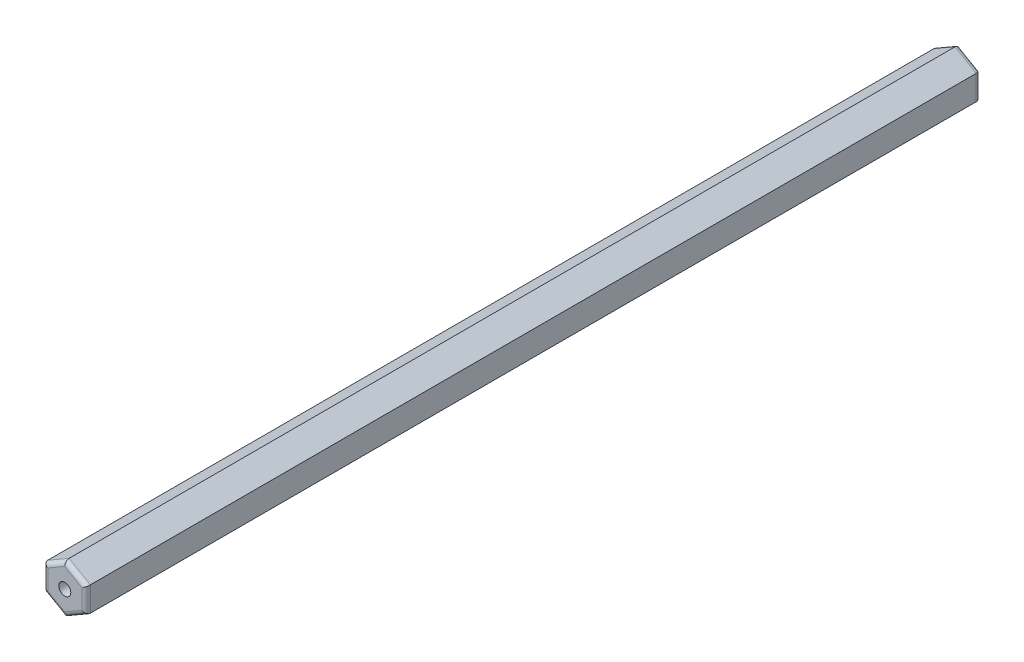
from build123d import *

# Parameters (mm, degrees)
RESSALTO_EXTRUS_O1_DEPTH = 105
FILETE1_R                = 0.5
ESBO_O2_R                = 0.701481341
CORTE_EXTRUS_O1_DEPTH    = 106


with BuildPart() as part:
    # Esboço1 → Ressalto-extrusão1 (new body)
    with BuildSketch(Plane.XY.offset(135)):
        Polygon((-55.002122675, 2.886751346), (-57.502122675, 1.443375673), (-57.502122675, -1.443375673), (-55.002122675, -2.886751346), (-52.502122675, -1.443375673), (-52.502122675, 1.443375673), align=None)
    extrude(amount=-RESSALTO_EXTRUS_O1_DEPTH)

    # Filete1
    filete1_edges = [part.edges().sort_by_distance(p)[0] for p in [
        (-57.502122675, 0, 30),
        (-56.252122675, -2.165063509, 30),
        (-53.752122675, -2.165063509, 30),
        (-52.502122675, 0, 30),
        (-53.752122675, 2.165063509, 30),
        (-52.502122675, 0, 135),
        (-53.752122675, -2.165063509, 135),
        (-56.252122675, -2.165063509, 135),
        (-57.502122675, 0, 135),
        (-56.252122675, 2.165063509, 135),
        (-53.752122675, 2.165063509, 135),
        (-56.252122675, 2.165063509, 30),
    ]]
    fillet(filete1_edges, radius=FILETE1_R)

    # Esboço2 → Corte-extrusão1 (cut, through all)
    with BuildSketch(Plane.XY.offset(135)):
        with Locations((-55.002122675, 0)):
            Circle(ESBO_O2_R)
    extrude(amount=-CORTE_EXTRUS_O1_DEPTH, mode=Mode.SUBTRACT)


solid = part.part
